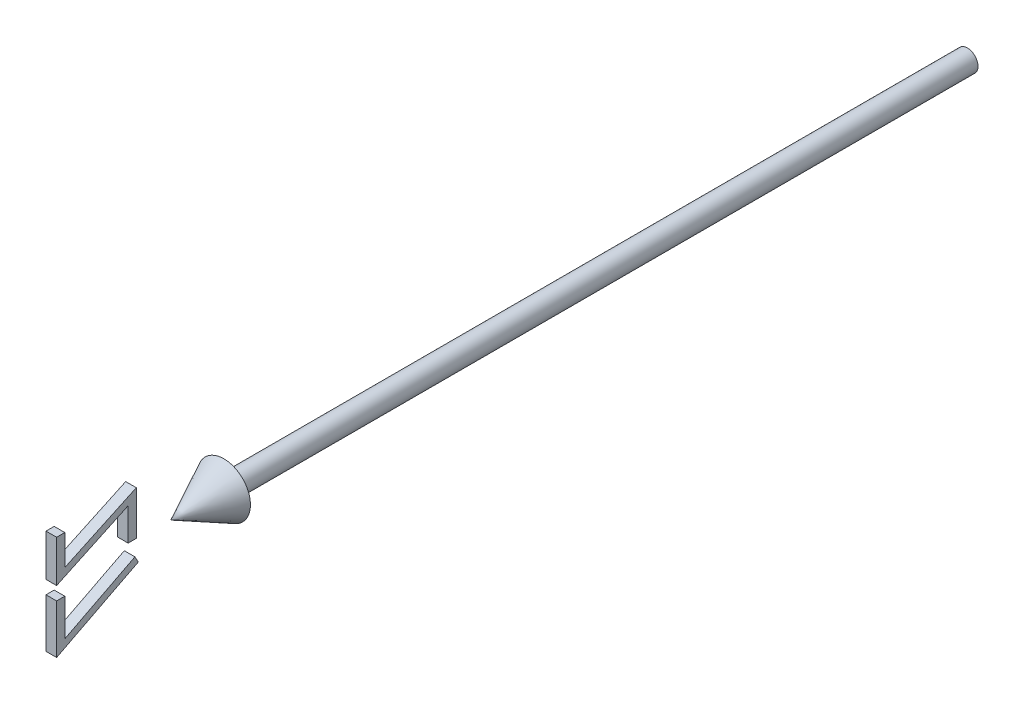
from build123d import *

# Parameters (mm, degrees)
BOSS_EXTRUDE1_DEPTH        = 1
BOSS_EXTRUDE1_DEPTH_BACK   = 1
BOSS_EXTRUDE1_2_DEPTH      = 1
BOSS_EXTRUDE1_2_DEPTH_BACK = 1


with BuildPart() as part:
    # Sketch2 → Revolve1 (revolve)
    with BuildSketch(Plane(origin=(0, 0, 0), x_dir=(1, 0, 0), z_dir=(0, 1, 0))):
        Polygon((0, -150), (5, -140), (2, -140), (2, 0), (0, 0), align=None)
    revolve(axis=Axis((0, 0, -41.949952025), (0, 0, 1)))


with BuildPart() as body_2:
    # Sketch3 → Boss-Extrude1 (new, two sides: drawn at the far end of the back side and taken through both)
    with BuildSketch(Plane(origin=(0, 0, 0), x_dir=(0, -1, 0), z_dir=(1, 0, 0)).offset(-BOSS_EXTRUDE1_DEPTH_BACK)):
        Polygon((-8.958586521, -170.961538462), (-8.958586521, -172.5), (-1.073971137, -172.5), (-7.366038444, -159.038461538), (-1.266278829, -159.038461538), (-1.266278829, -157.5), (-9.535509598, -157.5), (-3.243442291, -170.961538462), align=None)
    extrude(amount=BOSS_EXTRUDE1_DEPTH + BOSS_EXTRUDE1_DEPTH_BACK)


with BuildPart() as body_3:
    # Sketch3 → Boss-Extrude1 2 (new, two sides: drawn at the far end of the back side and taken through both)
    with BuildSketch(Plane(origin=(0, 0, 0), x_dir=(0, -1, 0), z_dir=(1, 0, 0)).offset(-BOSS_EXTRUDE1_2_DEPTH_BACK)):
        Polygon((1.426028863, -172.5), (10.656798094, -172.5), (2.772182709, -157.115384615), (1.609322133, -157.755408654), (8.379153863, -170.961538462), (1.426028863, -170.961538462), align=None)
    extrude(amount=BOSS_EXTRUDE1_2_DEPTH + BOSS_EXTRUDE1_2_DEPTH_BACK)


solid = Compound([part.part, body_2.part, body_3.part])
